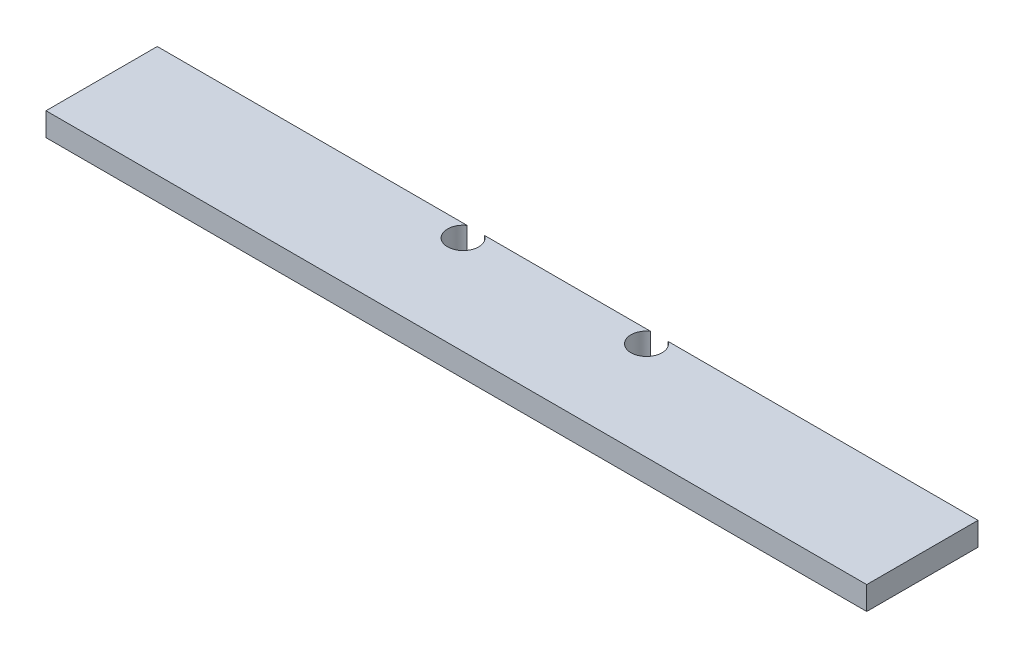
from build123d import *

# Parameters (mm, degrees)
SKETCH1_W           = 669.925
SKETCH1_H           = 90.8304
BOSS_EXTRUDE1_DEPTH = 19.05
SKETCH2_R           = 12.7
CUT_EXTRUDE4_DEPTH  = 20.05


with BuildPart() as part:
    # Sketch1 → Boss-Extrude1 (new body)
    with BuildSketch(Plane(origin=(0, 0, 0), x_dir=(1, 0, 0), z_dir=(0, 1, 0))):
        with Locations((334.9625, 45.4152)):
            Rectangle(SKETCH1_W, SKETCH1_H)
    extrude(amount=BOSS_EXTRUDE1_DEPTH)

    # Sketch2 → Cut-Extrude4 (cut, through all)
    with BuildSketch(Plane.XZ):
        with Locations((409.8036, -80.3402)):
            Circle(SKETCH2_R)
        with Locations((260.1214, -80.3402)):
            Circle(SKETCH2_R)
    extrude(amount=-CUT_EXTRUDE4_DEPTH, mode=Mode.SUBTRACT)


solid = part.part
